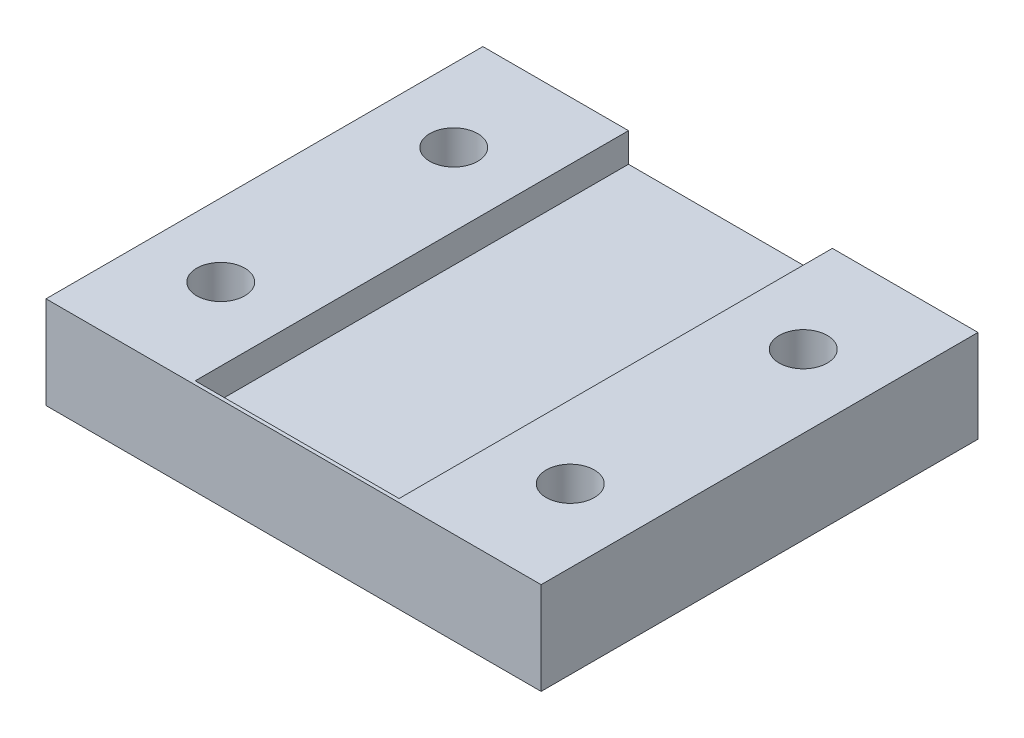
from build123d import *

# Parameters (mm, degrees)
SKETCH1_W           = 34
SKETCH1_H           = 6.35
BOSS_EXTRUDE2_DEPTH = 15
SKETCH3_R           = 1.65
CUT_EXTRUDE1_DEPTH  = 6.35
SKETCH4_W           = 14
SKETCH4_H           = 29.754966952
CUT_EXTRUDE2_DEPTH  = 2


with BuildPart() as part:
    # Sketch1 → Boss-Extrude2 (new body, symmetric)
    with BuildSketch(Plane.XY):
        with Locations((0, 3.175)):
            Rectangle(SKETCH1_W, SKETCH1_H)
    extrude(amount=BOSS_EXTRUDE2_DEPTH, both=True)

    # Sketch3 → Cut-Extrude1 (cut)
    with BuildSketch(Plane.XZ):
        with Locations((-12, 8)):
            Circle(SKETCH3_R)
        with Locations((12, 8)):
            Circle(SKETCH3_R)
        with Locations((-12, -8)):
            Circle(SKETCH3_R)
        with Locations((12, -8)):
            Circle(SKETCH3_R)
    extrude(amount=-CUT_EXTRUDE1_DEPTH, mode=Mode.SUBTRACT)

    # Sketch4 → Cut-Extrude2 (cut)
    with BuildSketch(Plane(origin=(0, 6.35, 0), x_dir=(1, 0, 0), z_dir=(0, 1, 0))):
        with Locations((0, 0.122516524)):
            Rectangle(SKETCH4_W, SKETCH4_H)
    extrude(amount=-CUT_EXTRUDE2_DEPTH, mode=Mode.SUBTRACT)


solid = part.part
